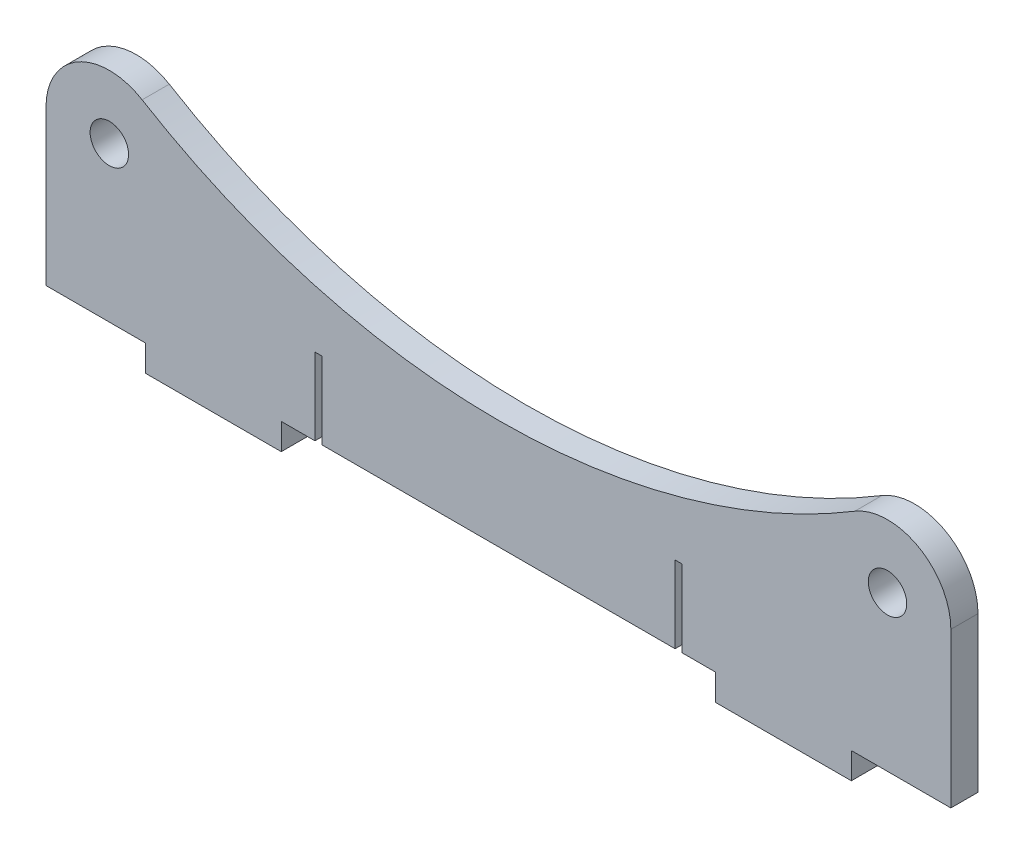
from build123d import *

# Parameters (mm, degrees)
ESBO_O1_R                = 4.25
RESSALTO_EXTRUS_O1_DEPTH = 6
ESBO_O2_W                = 1.5
ESBO_O2_H                = 20
CORTE_EXTRUS_O1_DEPTH    = 25.5


with BuildPart() as part:
    # Esboço1 → Ressalto-extrusão1 (new body)
    with BuildSketch(Plane.XY):
        with BuildLine():
            ThreePointArc((-78.750627195, 41.976919217), (-92.874182887, 42.196130929), (-100, 30))
            Line((-100, 30), (-100, -4.2))
            Line((-100, -4.2), (-78, -4.2))
            Line((-78, -4.2), (-78, -10))
            Line((-78, -10), (-48, -10))
            Line((-48, -10), (-48, -4.2))
            Line((-48, -4.2), (48, -4.2))
            Line((48, -4.2), (48, -10))
            Line((48, -10), (78, -10))
            Line((78, -10), (78, -4.2))
            Line((78, -4.2), (100, -4.2))
            Line((100, -4.2), (100, 30))
            ThreePointArc((100, 30), (92.874182887, 42.196130929), (78.750627195, 41.976919217))
            ThreePointArc((78.750627195, 41.976919217), (0, 20), (-78.750627195, 41.976919217))
        make_face()
        with Locations((-86, 30)):
            Circle(ESBO_O1_R, mode=Mode.SUBTRACT)
        with Locations((86, 30)):
            Circle(ESBO_O1_R, mode=Mode.SUBTRACT)
    extrude(amount=RESSALTO_EXTRUS_O1_DEPTH)

    # Esboço2 → Corte-extrusão1 (cut)
    with BuildSketch(Plane.XY.offset(6)):
        with Locations((-39.8, 2.8)):
            Rectangle(ESBO_O2_W, ESBO_O2_H)
        with Locations((39.8, 2.8)):
            Rectangle(ESBO_O2_W, ESBO_O2_H)
    extrude(amount=-CORTE_EXTRUS_O1_DEPTH, mode=Mode.SUBTRACT)


solid = part.part
